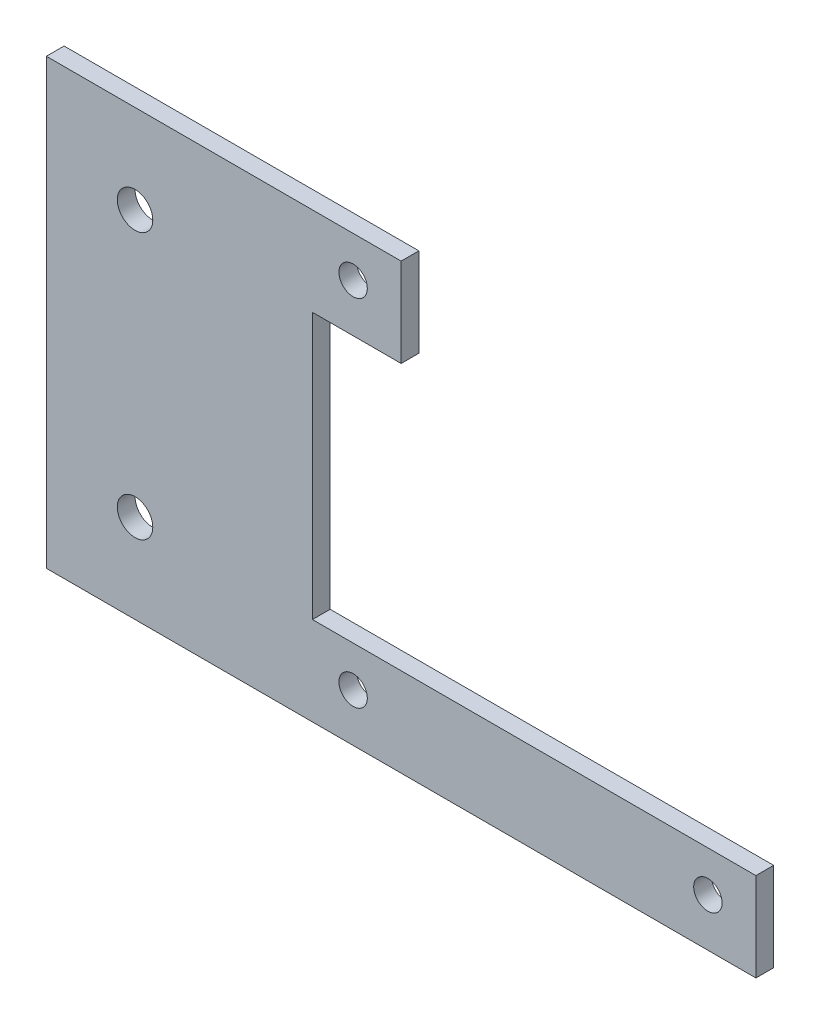
from build123d import *

# Parameters (mm, degrees)
SKETCH2_R           = 1.6
SKETCH2_R_2         = 2
BOSS_EXTRUDE1_DEPTH = 2


with BuildPart() as part:
    # Sketch2 → Boss-Extrude1 (new body)
    with BuildSketch(Plane.XY):
        Polygon((-10, -34.944055233), (-10, -84.944055233), (70, -84.944055233), (70, -74.944055233), (20, -74.944055233), (20, -44.944055233), (30, -44.944055233), (30, -34.944055233), align=None)
        with Locations((24.587187523, -39.531242756)):
            Circle(SKETCH2_R, mode=Mode.SUBTRACT)
        with Locations((24.587187523, -79.531242756)):
            Circle(SKETCH2_R, mode=Mode.SUBTRACT)
        with Locations((64.587187523, -79.531242756)):
            Circle(SKETCH2_R, mode=Mode.SUBTRACT)
        with Locations((0, -74.944055233)):
            Circle(SKETCH2_R_2, mode=Mode.SUBTRACT)
        with Locations((0, -44.944055233)):
            Circle(SKETCH2_R_2, mode=Mode.SUBTRACT)
    extrude(amount=BOSS_EXTRUDE1_DEPTH)


solid = part.part
